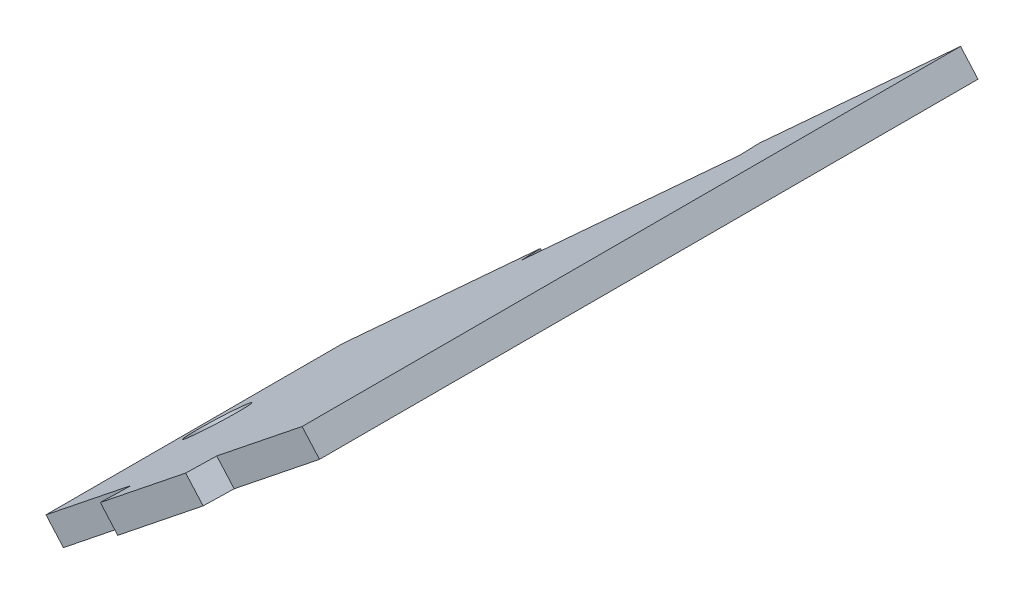
from build123d import *

# Parameters (mm, degrees)
BOSS_EXTRUDE1_DEPTH  = 1.6
M3_CLEARANCE_HOLE1_D = 3.4


with BuildPart() as part:
    # Sketch5 → Boss-Extrude1 (new body)
    with BuildSketch(Plane(origin=(9.507139376, -10.778899957, 0), x_dir=(0, 0, -1), z_dir=(0.6614786524658173, -0.7499639940237175, 0))):
        Polygon((-18.324577301, 51.705324763), (21.675422699, 51.705324763), (18.090793802, 40.16602452), (16.562821188, 40.640681966), (12.673658844, 28.121056286), (14.201631457, 27.64639884), (10.675422699, 16.295159211), (9, 16.295159211), (-7.324577301, 16.295159211), (-10.991243968, 28.098547728), (-12.519216582, 27.623890282), (-16.185883249, 39.427278799), (-14.657910635, 39.901936245), align=None)
    extrude(amount=BOSS_EXTRUDE1_DEPTH)

    # M3 Clearance Hole1 (through all)
    with Locations(Plane(origin=(9.507139376, -10.778899957, 0), x_dir=(0.7499639940237175, 0.6614786524658175, 0), z_dir=(-0.6614786524658175, 0.7499639940237175, 0))):
        with Locations((19.295159211, 0.837711349)):
            Hole(M3_CLEARANCE_HOLE1_D / 2)


solid = part.part
